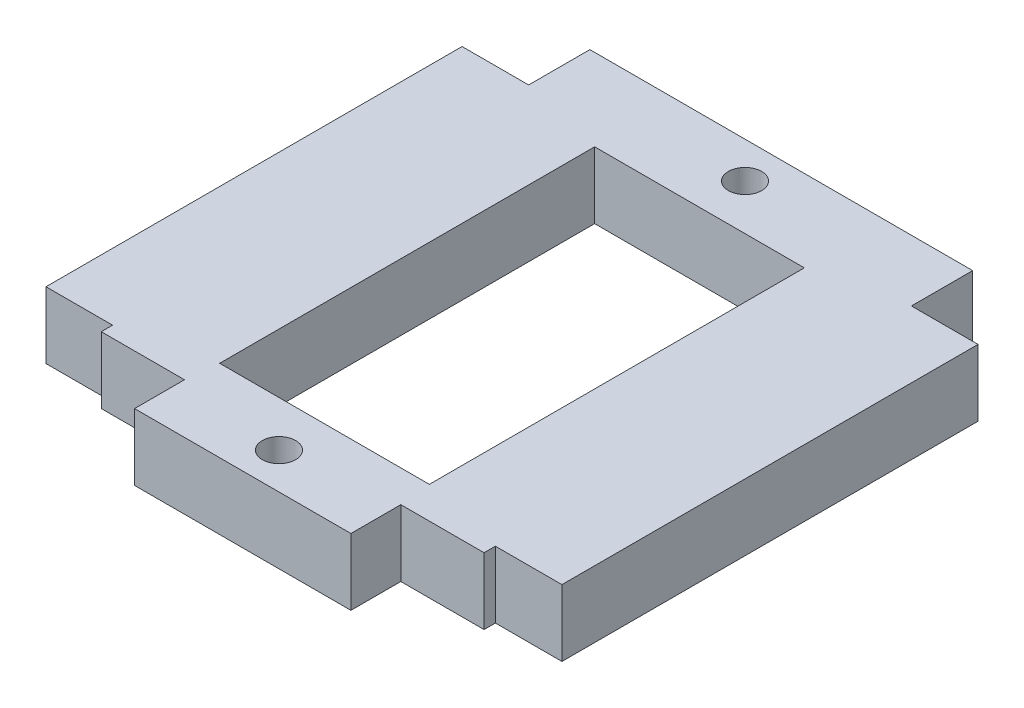
from build123d import *

# Parameters (mm, degrees)
CROQUIS1_R              = 1
CROQUIS1_W              = 12.5984
CROQUIS1_H              = 22.5298
SALIENTE_EXTRUIR1_DEPTH = 4


with BuildPart() as part:
    # Croquis1 → Saliente-Extruir1 (new body)
    with BuildSketch(Plane(origin=(0, 0, 0), x_dir=(1, 0, 0), z_dir=(0, 1, 0))):
        Polygon((-6.5, -11.2141), (-6.2992, -11.2141), (6.5, -11.2141), (6.5, -8.2141), (11.5, -8.2141), (11.5, -7.5343), (15.5, -7.5343), (15.5, 17.4657), (11.5, 17.4657), (11.5, 21.1455), (-11.5, 21.1455), (-11.5, 17.4657), (-15.5, 17.4657), (-15.5, -7.5343), (-11.5, -7.5343), (-11.5, -8.2141), (-6.5, -8.2141), align=None)
        with Locations((0, -9.036)):
            Circle(CROQUIS1_R, mode=Mode.SUBTRACT)
        with Locations((0, 4.9657)):
            Rectangle(CROQUIS1_W, CROQUIS1_H, mode=Mode.SUBTRACT)
        with Locations((0, 18.9674)):
            Circle(CROQUIS1_R, mode=Mode.SUBTRACT)
    extrude(amount=SALIENTE_EXTRUIR1_DEPTH)


solid = part.part
